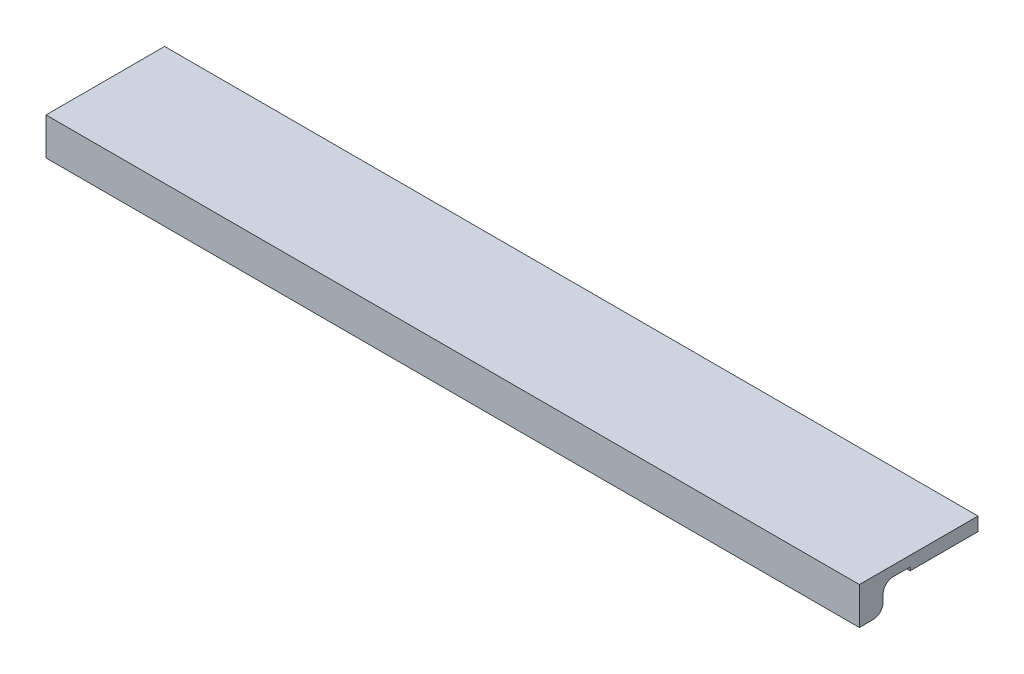
from build123d import *

# Parameters (mm, degrees)
SKETCH1_W           = 240
SKETCH1_H           = 35
BOSS_EXTRUDE1_DEPTH = 3
SKETCH3_W           = 240
SKETCH3_H           = 7
BOSS_EXTRUDE3_DEPTH = 8
FILLET1_R           = 3
SKETCH4_W           = 240
SKETCH4_H           = 7
BOSS_EXTRUDE5_DEPTH = 20
CHAMFER1_SIZE       = 10
CHAMFER1_SIZE2      = 6


with BuildPart() as part:
    # Sketch1 → Boss-Extrude1 (new body)
    with BuildSketch(Plane(origin=(0, 0, 0), x_dir=(1, 0, 0), z_dir=(0, 1, 0))):
        Rectangle(SKETCH1_W, SKETCH1_H)
    extrude(amount=BOSS_EXTRUDE1_DEPTH)

    # Sketch3 → Boss-Extrude3 (add)
    with BuildSketch(Plane.XZ):
        with Locations((0, 14)):
            Rectangle(SKETCH3_W, SKETCH3_H)
    extrude(amount=BOSS_EXTRUDE3_DEPTH)

    # Fillet1
    fillet1_edges = [part.edges().sort_by_distance(p)[0] for p in [
        (0, 0, 10.5),
        (0, -8, 10.5),
    ]]
    fillet(fillet1_edges, radius=FILLET1_R)

    # Sketch4 → Boss-Extrude5 (add)
    with BuildSketch(Plane(origin=(0, 0, -17.5), x_dir=(-1, 0, 0), z_dir=(0, 0, -1))):
        with Locations((0, -3.5)):
            Rectangle(SKETCH4_W, SKETCH4_H)
    extrude(amount=-BOSS_EXTRUDE5_DEPTH)

    # Chamfer1
    chamfer1_edges = [part.edges().sort_by_distance(p)[0] for p in [
        (0, -7, 2.5),
        (-120, -7, -7.5),
        (120, -7, -7.5),
    ]]
    chamfer1_side = [part.faces().sort_by_distance(p)[0] for p in [
        (0, -7, -7.5),
    ]]
    chamfer(chamfer1_edges, length=CHAMFER1_SIZE, length2=CHAMFER1_SIZE2, reference=chamfer1_side[0])


solid = part.part
